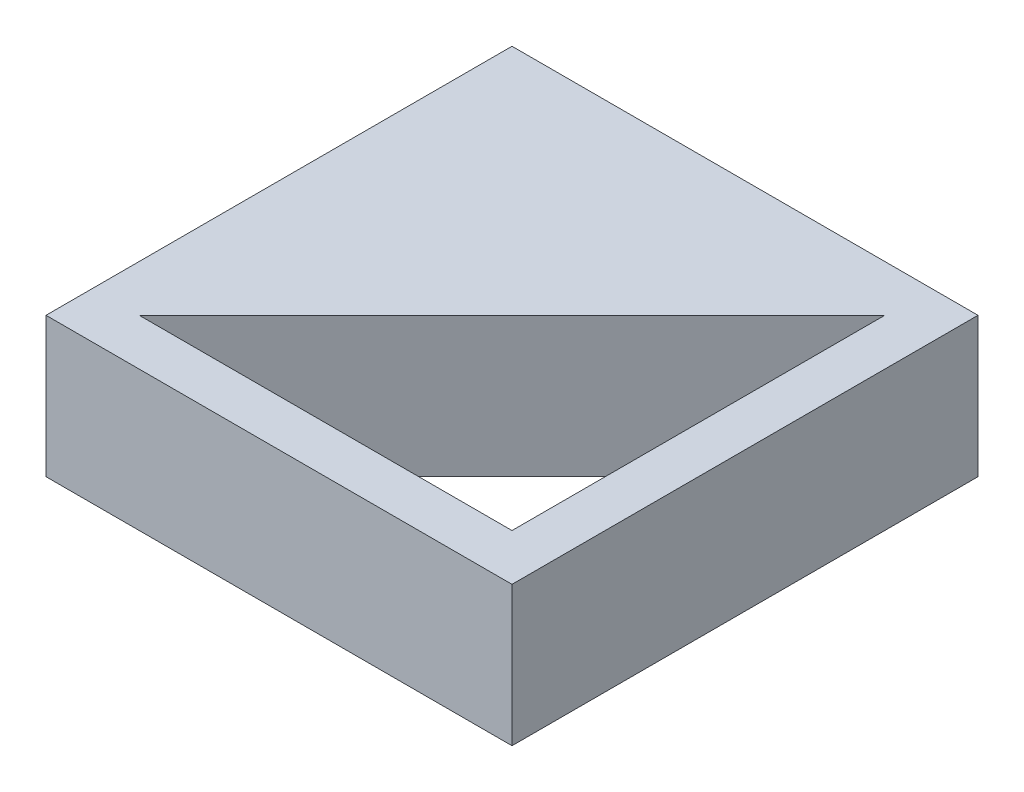
from build123d import *

# Parameters (mm, degrees)
SKETCH1_W           = 100
SKETCH1_H           = 100
BOSS_EXTRUDE1_DEPTH = 30
CUT_EXTRUDE1_DEPTH  = 31


with BuildPart() as part:
    # Sketch1 → Boss-Extrude1 (new body)
    with BuildSketch(Plane(origin=(0, 0, 0), x_dir=(1, 0, 0), z_dir=(0, 1, 0))):
        Rectangle(SKETCH1_W, SKETCH1_H)
    extrude(amount=BOSS_EXTRUDE1_DEPTH)

    # Sketch2 → Cut-Extrude1 (cut, through all)
    with BuildSketch(Plane(origin=(0, 30, 0), x_dir=(1, 0, 0), z_dir=(0, 1, 0))):
        Polygon((40, 40), (40, -40), (-40, -40), align=None)
    extrude(amount=-CUT_EXTRUDE1_DEPTH, mode=Mode.SUBTRACT)


solid = part.part
